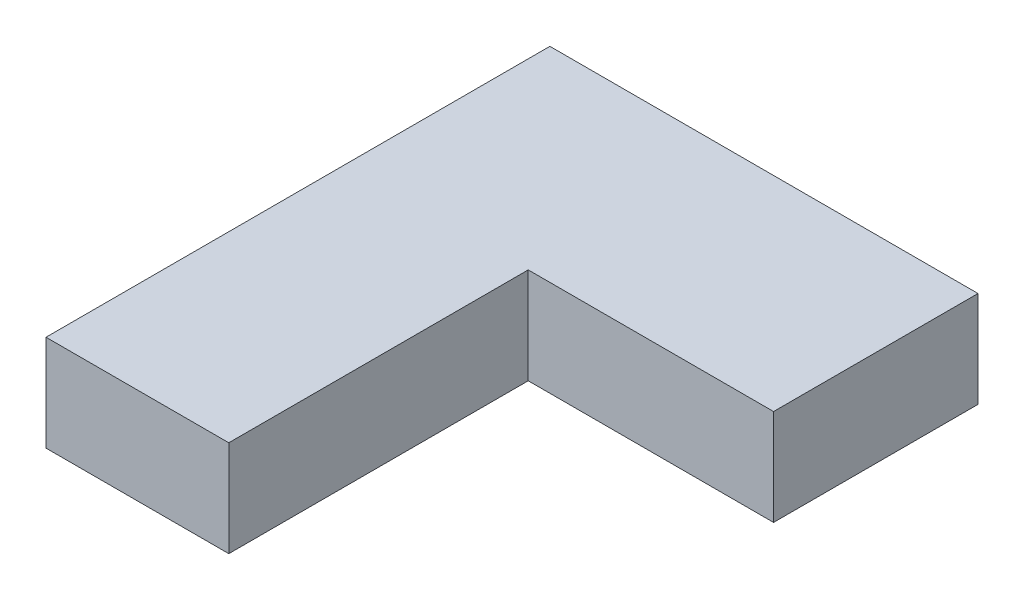
from build123d import *

# Parameters (mm, degrees)
BOSS_EXTRUDE1_DEPTH = 10


with BuildPart() as part:
    # Sketch1 → Boss-Extrude1 (new body)
    with BuildSketch(Plane(origin=(0, 0, 0), x_dir=(1, 0, 0), z_dir=(0, 1, 0))):
        Polygon((0, 0), (0, 52.456223719), (44.569011084, 52.456223719), (44.569011084, 31.173268988), (19.029465407, 31.173268988), (19.029465407, 0), align=None)
    extrude(amount=BOSS_EXTRUDE1_DEPTH)


solid = part.part
